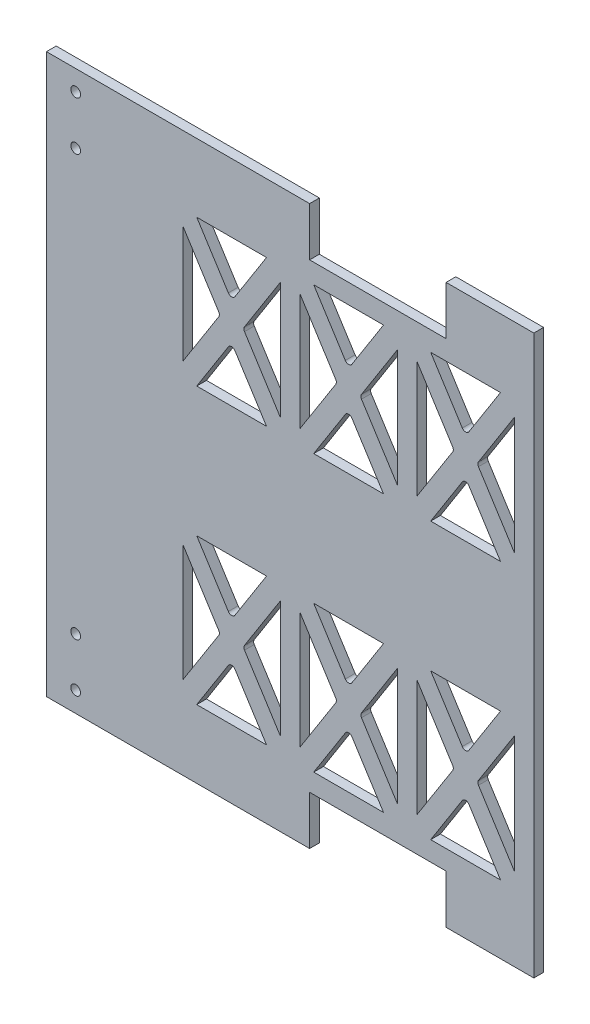
from build123d import *

# Parameters (mm, degrees)
SKETCH2_W           = 250
SKETCH2_H           = 286.5
BOSS_EXTRUDE1_DEPTH = 5
SKETCH3_R           = 2.5
SKETCH3_W           = 70
SKETCH3_H           = 25
CUT_EXTRUDE1_DEPTH  = 5


with BuildPart() as part:
    # Sketch2 → Boss-Extrude1 (new body)
    with BuildSketch(Plane.XY):
        Rectangle(SKETCH2_W, SKETCH2_H)
    extrude(amount=BOSS_EXTRUDE1_DEPTH)

    # Sketch3 → Cut-Extrude1 (cut)
    with BuildSketch(Plane.XY.offset(5)):
        with Locations((-110, -132.85)):
            Circle(SKETCH3_R)
        with Locations((-110, -107.85)):
            Circle(SKETCH3_R)
        with Locations((-110, 132.85)):
            Circle(SKETCH3_R)
        with Locations((-110, 107.85)):
            Circle(SKETCH3_R)
        with Locations((45, -130.75)):
            Rectangle(SKETCH3_W, SKETCH3_H)
        with Locations((45, 130.75)):
            Rectangle(SKETCH3_W, SKETCH3_H)
        with BuildLine():
            Line((28.31193033, 58.769897179), (12.096931793, 33.25))
            Line((12.096931793, 33.25), (47.903068207, 33.25))
            Line((47.903068207, 33.25), (31.68806967, 58.769897179))
            ThreePointArc((31.68806967, 58.769897179), (30, 59.697320474), (28.31193033, 58.769897179))
        make_face()
        with BuildLine():
            Line((23.394573112, 71.822576705), (5, 100.772786809))
            Line((5, 100.772786809), (5, 40.727213191))
            Line((5, 40.727213191), (23.394573112, 69.677423295))
            ThreePointArc((23.394573112, 69.677423295), (23.706503442, 70.75), (23.394573112, 71.822576705))
        make_face()
        with BuildLine():
            Line((47.903068207, 108.25), (12.096931793, 108.25))
            Line((12.096931793, 108.25), (28.31193033, 82.730102821))
            ThreePointArc((28.31193033, 82.730102821), (30, 81.802679526), (31.68806967, 82.730102821))
            Line((31.68806967, 82.730102821), (47.903068207, 108.25))
        make_face()
        with BuildLine():
            Line((-12.096931793, 108.25), (-47.903068207, 108.25))
            Line((-47.903068207, 108.25), (-31.68806967, 82.730102821))
            ThreePointArc((-31.68806967, 82.730102821), (-30, 81.802679526), (-28.31193033, 82.730102821))
            Line((-28.31193033, 82.730102821), (-12.096931793, 108.25))
        make_face()
        with BuildLine():
            Line((-5, 40.727213191), (-5, 100.772786809))
            Line((-5, 100.772786809), (-23.394573112, 71.822576705))
            ThreePointArc((-23.394573112, 71.822576705), (-23.706503442, 70.75), (-23.394573112, 69.677423295))
            Line((-23.394573112, 69.677423295), (-5, 40.727213191))
        make_face()
        with BuildLine():
            Line((-36.605426888, 71.822576705), (-55, 100.772786809))
            Line((-55, 100.772786809), (-55, 40.727213191))
            Line((-55, 40.727213191), (-36.605426888, 69.677423295))
            ThreePointArc((-36.605426888, 69.677423295), (-36.293496558, 70.75), (-36.605426888, 71.822576705))
        make_face()
        with BuildLine():
            Line((-31.68806967, 58.769897179), (-47.903068207, 33.25))
            Line((-47.903068207, 33.25), (-12.096931793, 33.25))
            Line((-12.096931793, 33.25), (-28.31193033, 58.769897179))
            ThreePointArc((-28.31193033, 58.769897179), (-30, 59.697320474), (-31.68806967, 58.769897179))
        make_face()
        with BuildLine():
            Line((55, 40.727213191), (55, 100.772786809))
            Line((55, 100.772786809), (36.605426888, 71.822576705))
            ThreePointArc((36.605426888, 71.822576705), (36.293496558, 70.75), (36.605426888, 69.677423295))
            Line((36.605426888, 69.677423295), (55, 40.727213191))
        make_face()
        with BuildLine():
            Line((-12.096931793, -33.25), (-47.903068207, -33.25))
            Line((-47.903068207, -33.25), (-31.68806967, -58.769897179))
            ThreePointArc((-31.68806967, -58.769897179), (-30, -59.697320474), (-28.31193033, -58.769897179))
            Line((-28.31193033, -58.769897179), (-12.096931793, -33.25))
        make_face()
        with BuildLine():
            Line((-36.605426888, -69.677423295), (-55, -40.727213191))
            Line((-55, -40.727213191), (-55, -100.772786809))
            Line((-55, -100.772786809), (-36.605426888, -71.822576705))
            ThreePointArc((-36.605426888, -71.822576705), (-36.293496558, -70.75), (-36.605426888, -69.677423295))
        make_face()
        with BuildLine():
            Line((-31.68806967, -82.730102821), (-47.903068207, -108.25))
            Line((-47.903068207, -108.25), (-12.096931793, -108.25))
            Line((-12.096931793, -108.25), (-28.31193033, -82.730102821))
            ThreePointArc((-28.31193033, -82.730102821), (-30, -81.802679526), (-31.68806967, -82.730102821))
        make_face()
        with BuildLine():
            Line((-5, -100.772786809), (-5, -40.727213191))
            Line((-5, -40.727213191), (-23.394573112, -69.677423295))
            ThreePointArc((-23.394573112, -69.677423295), (-23.706503442, -70.75), (-23.394573112, -71.822576705))
            Line((-23.394573112, -71.822576705), (-5, -100.772786809))
        make_face()
        with BuildLine():
            Line((23.394573112, -69.677423295), (5, -40.727213191))
            Line((5, -40.727213191), (5, -100.772786809))
            Line((5, -100.772786809), (23.394573112, -71.822576705))
            ThreePointArc((23.394573112, -71.822576705), (23.706503442, -70.75), (23.394573112, -69.677423295))
        make_face()
        with BuildLine():
            Line((47.903068207, -33.25), (12.096931793, -33.25))
            Line((12.096931793, -33.25), (28.31193033, -58.769897179))
            ThreePointArc((28.31193033, -58.769897179), (30, -59.697320474), (31.68806967, -58.769897179))
            Line((31.68806967, -58.769897179), (47.903068207, -33.25))
        make_face()
        with BuildLine():
            Line((55, -100.772786809), (55, -40.727213191))
            Line((55, -40.727213191), (36.605426888, -69.677423295))
            ThreePointArc((36.605426888, -69.677423295), (36.293496558, -70.75), (36.605426888, -71.822576705))
            Line((36.605426888, -71.822576705), (55, -100.772786809))
        make_face()
        with BuildLine():
            Line((28.31193033, -82.730102821), (12.096931793, -108.25))
            Line((12.096931793, -108.25), (47.903068207, -108.25))
            Line((47.903068207, -108.25), (31.68806967, -82.730102821))
            ThreePointArc((31.68806967, -82.730102821), (30, -81.802679526), (28.31193033, -82.730102821))
        make_face()
        with BuildLine():
            Line((83.394573112, -69.677423295), (65, -40.727213191))
            Line((65, -40.727213191), (65, -100.772786809))
            Line((65, -100.772786809), (83.394573112, -71.822576705))
            ThreePointArc((83.394573112, -71.822576705), (83.706503442, -70.75), (83.394573112, -69.677423295))
        make_face()
        with BuildLine():
            Line((107.903068207, -33.25), (72.096931793, -33.25))
            Line((72.096931793, -33.25), (88.31193033, -58.769897179))
            ThreePointArc((88.31193033, -58.769897179), (90, -59.697320474), (91.68806967, -58.769897179))
            Line((91.68806967, -58.769897179), (107.903068207, -33.25))
        make_face()
        with BuildLine():
            Line((115, -100.772786809), (115, -40.727213191))
            Line((115, -40.727213191), (96.605426888, -69.677423295))
            ThreePointArc((96.605426888, -69.677423295), (96.293496558, -70.75), (96.605426888, -71.822576705))
            Line((96.605426888, -71.822576705), (115, -100.772786809))
        make_face()
        with BuildLine():
            Line((88.31193033, -82.730102821), (72.096931793, -108.25))
            Line((72.096931793, -108.25), (107.903068207, -108.25))
            Line((107.903068207, -108.25), (91.68806967, -82.730102821))
            ThreePointArc((91.68806967, -82.730102821), (90, -81.802679526), (88.31193033, -82.730102821))
        make_face()
        with BuildLine():
            Line((115, 40.727213191), (115, 100.772786809))
            Line((115, 100.772786809), (96.605426888, 71.822576705))
            ThreePointArc((96.605426888, 71.822576705), (96.293496558, 70.75), (96.605426888, 69.677423295))
            Line((96.605426888, 69.677423295), (115, 40.727213191))
        make_face()
        with BuildLine():
            Line((91.68806967, 82.730102821), (107.903068207, 108.25))
            Line((107.903068207, 108.25), (72.096931793, 108.25))
            Line((72.096931793, 108.25), (88.31193033, 82.730102821))
            ThreePointArc((88.31193033, 82.730102821), (90, 81.802679526), (91.68806967, 82.730102821))
        make_face()
        with BuildLine():
            Line((83.394573112, 71.822576705), (65, 100.772786809))
            Line((65, 100.772786809), (65, 40.727213191))
            Line((65, 40.727213191), (83.394573112, 69.677423295))
            ThreePointArc((83.394573112, 69.677423295), (83.706503442, 70.75), (83.394573112, 71.822576705))
        make_face()
        with BuildLine():
            Line((72.096931793, 33.25), (107.903068207, 33.25))
            Line((107.903068207, 33.25), (91.68806967, 58.769897179))
            ThreePointArc((91.68806967, 58.769897179), (90, 59.697320474), (88.31193033, 58.769897179))
            Line((88.31193033, 58.769897179), (72.096931793, 33.25))
        make_face()
    extrude(amount=-CUT_EXTRUDE1_DEPTH, mode=Mode.SUBTRACT)


solid = part.part
